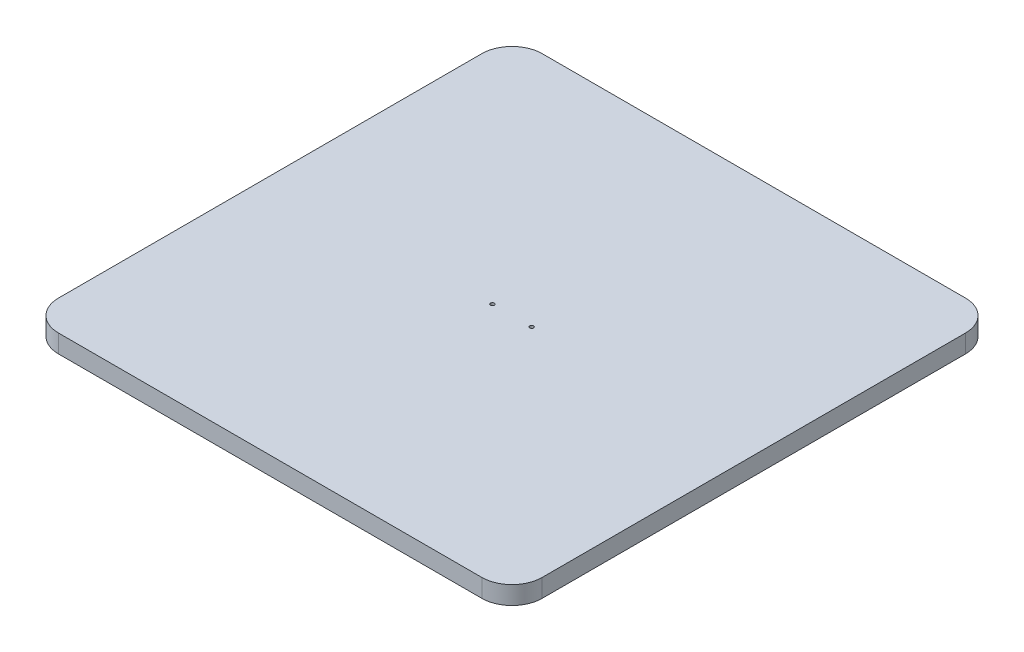
from build123d import *

# Parameters (mm, degrees)
SKETCH1_W           = 160
SKETCH1_H           = 160
MAIN_BODY_DEPTH     = 6
M1_6_TAPPED_HOLE1_D = 1.25
FILLET1_R           = 10


with BuildPart() as part:
    # Sketch1 → main body (new body)
    with BuildSketch(Plane(origin=(0, 0, 0), x_dir=(1, 0, 0), z_dir=(0, 1, 0))):
        Rectangle(SKETCH1_W, SKETCH1_H)
    extrude(amount=MAIN_BODY_DEPTH)

    # M1.6 Tapped Hole1 (through all)
    with Locations(Plane(origin=(0, 6, 0), x_dir=(1, 0, 0), z_dir=(0, 1, 0))):
        with Locations((6.5, 0), (-6.5, 0)):
            Hole(M1_6_TAPPED_HOLE1_D / 2)

    # Fillet1
    fillet1_edges = [part.edges().sort_by_distance(p)[0] for p in [
        (-80, 3, -80),
        (80, 3, -80),
        (80, 3, 80),
        (-80, 3, 80),
    ]]
    fillet(fillet1_edges, radius=FILLET1_R)


solid = part.part
